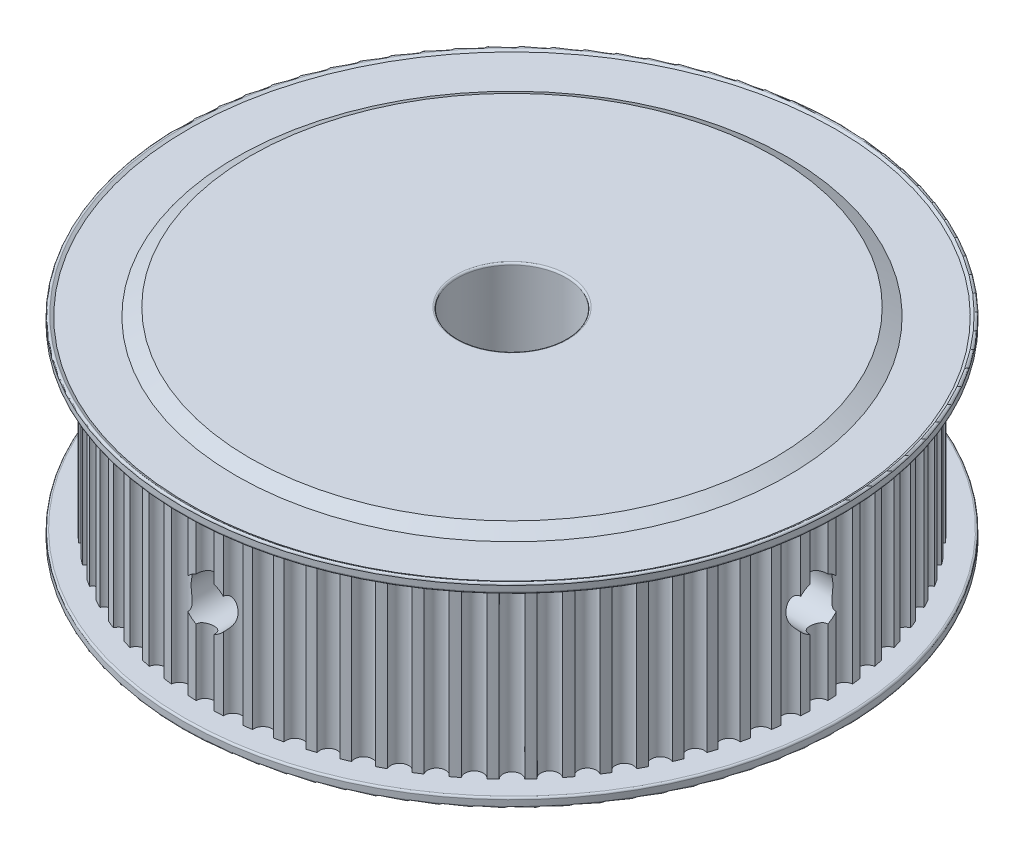
from build123d import *

# Parameters (mm, degrees)
FILLET1_R            = 0.2
BOSS_EXTRUDE1_DEPTH  = 19.5
FILLET1_OF_MIRROR1_R = 0.2
SKETCH4_R            = 2.6
CUT_EXTRUDE1_DEPTH   = 36.5
SKETCH5_R            = 2.6
CUT_EXTRUDE2_DEPTH   = 36.5
SKETCH3_R            = 6
CUT_EXTRUDE3_DEPTH   = 24
FILLET2_R            = 0.2
SCALE2_SCALE         = 0.2


with BuildPart() as part:
    # Sketch1 → Revolve1 (revolve)
    with BuildSketch(Plane.XY):
        Polygon((0, 0), (0, 1.75), (36.5, 1.75), (36.5, 0.55), (35.893782217, 0.9), (30.558845727, 0.9), (29, 0), align=None)
    revolve1 = revolve(axis=Axis((0, 0, 0), (0, 1, 0)))

    # Fillet1
    fillet1_edges = [part.edges().sort_by_distance(p)[0] for p in [
        (-36.5, 0.55, 0),
        (-36.5, 1.75, 0),
    ]]
    fillet(fillet1_edges, radius=FILLET1_R)

    # Sketch2 → Boss-Extrude1 (add)
    with BuildSketch(Plane(origin=(0, 1.75, 0), x_dir=(1, 0, 0), z_dir=(0, 1, 0))):
        with BuildLine():
            ThreePointArc((1.965926579, 33.943116131), (1.48305917, 33.967639534), (0.999891863, 33.985294118))
            ThreePointArc((0.999891863, 33.985294118), (0, 33), (-0.999891863, 33.985294118))
            ThreePointArc((-0.999891863, 33.985294118), (-1.48305917, 33.967639534), (-1.965926579, 33.943116131))
            ThreePointArc((-1.965926579, 33.943116131), (-2.876139511, 32.874425037), (-3.958100524, 33.768823495))
            ThreePointArc((-3.958100524, 33.768823495), (-4.437890535, 33.709125287), (-4.916783132, 33.642610535))
            ThreePointArc((-4.916783132, 33.642610535), (-5.730389863, 32.498655849), (-6.88618565, 33.295351736))
            ThreePointArc((-6.88618565, 33.295351736), (-7.358946874, 33.194064242), (-7.830219997, 33.086064359))
            ThreePointArc((-7.830219997, 33.086064359), (-8.541028488, 31.875552268), (-9.761862745, 32.568482245))
            ThreePointArc((-9.761862745, 32.568482245), (-10.223997183, 32.426376325), (-10.68406416, 32.277713256))
            ThreePointArc((-10.68406416, 32.277713256), (-11.28666473, 31.009856486), (-12.56324617, 31.593746939))
            ThreePointArc((-12.56324617, 31.593746939), (-13.0112367, 31.411904105), (-13.456596143, 31.223709264))
            ThreePointArc((-13.456596143, 31.223709264), (-13.946402637, 29.908156972), (-15.269015706, 30.378564143))
            ThreePointArc((-15.269015706, 30.378564143), (-15.69945285, 30.158368328), (-16.126715305, 29.932073992))
            ThreePointArc((-16.126715305, 29.932073992), (-16.5, 28.578838325), (-17.858578813, 28.93218213))
            ThreePointArc((-17.858578813, 28.93218213), (-18.268186684, 28.675309158), (-18.674100425, 28.412637564))
            ThreePointArc((-18.674100425, 28.412637564), (-18.9280224, 27.032017462), (-20.312227352, 27.265608741))
            ThreePointArc((-20.312227352, 27.265608741), (-20.697888586, 26.97401357), (-21.079364365, 26.676963807))
            ThreePointArc((-21.079364365, 26.676963807), (-21.21199112, 25.279466623), (-22.611287575, 25.391527606))
            ThreePointArc((-22.611287575, 25.391527606), (-22.970067059, 25.067429452), (-23.324201615, 24.738262248))
            ThreePointArc((-23.324201615, 24.738262248), (-23.334523779, 23.334523779), (-24.738262248, 23.324201615))
            ThreePointArc((-24.738262248, 23.324201615), (-25.067429452, 22.970067059), (-25.391527606, 22.611287575))
            ThreePointArc((-25.391527606, 22.611287575), (-25.279466623, 21.21199112), (-26.676963807, 21.079364365))
            ThreePointArc((-26.676963807, 21.079364365), (-26.97401357, 20.697888586), (-27.265608741, 20.312227352))
            ThreePointArc((-27.265608741, 20.312227352), (-27.032017462, 18.9280224), (-28.412637564, 18.674100425))
            ThreePointArc((-28.412637564, 18.674100425), (-28.675309158, 18.268186684), (-28.93218213, 17.858578813))
            ThreePointArc((-28.93218213, 17.858578813), (-28.578838325, 16.5), (-29.932073992, 16.126715305))
            ThreePointArc((-29.932073992, 16.126715305), (-30.158368328, 15.69945285), (-30.378564143, 15.269015706))
            ThreePointArc((-30.378564143, 15.269015706), (-29.908156972, 13.946402637), (-31.223709264, 13.456596143))
            ThreePointArc((-31.223709264, 13.456596143), (-31.411904105, 13.0112367), (-31.593746939, 12.56324617))
            ThreePointArc((-31.593746939, 12.56324617), (-31.009856486, 11.28666473), (-32.277713256, 10.68406416))
            ThreePointArc((-32.277713256, 10.68406416), (-32.426376325, 10.223997183), (-32.568482245, 9.761862745))
            ThreePointArc((-32.568482245, 9.761862745), (-31.875552268, 8.541028488), (-33.086064359, 7.830219997))
            ThreePointArc((-33.086064359, 7.830219997), (-33.194064242, 7.358946874), (-33.295351736, 6.88618565))
            ThreePointArc((-33.295351736, 6.88618565), (-32.498655849, 5.730389863), (-33.642610535, 4.916783132))
            ThreePointArc((-33.642610535, 4.916783132), (-33.709125287, 4.437890535), (-33.768823495, 3.958100524))
            ThreePointArc((-33.768823495, 3.958100524), (-32.874425037, 2.876139511), (-33.943116131, 1.965926579))
            ThreePointArc((-33.943116131, 1.965926579), (-33.967639534, 1.48305917), (-33.985294118, 0.999891863))
            ThreePointArc((-33.985294118, 0.999891863), (-33, 0), (-33.985294118, -0.999891863))
            ThreePointArc((-33.985294118, -0.999891863), (-33.967639534, -1.48305917), (-33.943116131, -1.965926579))
            ThreePointArc((-33.943116131, -1.965926579), (-32.874425037, -2.876139511), (-33.768823495, -3.958100524))
            ThreePointArc((-33.768823495, -3.958100524), (-33.709125287, -4.437890535), (-33.642610535, -4.916783132))
            ThreePointArc((-33.642610535, -4.916783132), (-32.498655849, -5.730389863), (-33.295351736, -6.88618565))
            ThreePointArc((-33.295351736, -6.88618565), (-33.194064242, -7.358946874), (-33.086064359, -7.830219997))
            ThreePointArc((-33.086064359, -7.830219997), (-31.875552268, -8.541028488), (-32.568482245, -9.761862745))
            ThreePointArc((-32.568482245, -9.761862745), (-32.426376325, -10.223997183), (-32.277713256, -10.68406416))
            ThreePointArc((-32.277713256, -10.68406416), (-31.009856486, -11.28666473), (-31.593746939, -12.56324617))
            ThreePointArc((-31.593746939, -12.56324617), (-31.411904105, -13.0112367), (-31.223709264, -13.456596143))
            ThreePointArc((-31.223709264, -13.456596143), (-29.908156972, -13.946402637), (-30.378564143, -15.269015706))
            ThreePointArc((-30.378564143, -15.269015706), (-30.158368328, -15.69945285), (-29.932073992, -16.126715305))
            ThreePointArc((-29.932073992, -16.126715305), (-28.578838325, -16.5), (-28.93218213, -17.858578813))
            ThreePointArc((-28.93218213, -17.858578813), (-28.675309158, -18.268186684), (-28.412637564, -18.674100425))
            ThreePointArc((-28.412637564, -18.674100425), (-27.032017462, -18.9280224), (-27.265608741, -20.312227352))
            ThreePointArc((-27.265608741, -20.312227352), (-26.97401357, -20.697888586), (-26.676963807, -21.079364365))
            ThreePointArc((-26.676963807, -21.079364365), (-25.279466623, -21.21199112), (-25.391527606, -22.611287575))
            ThreePointArc((-25.391527606, -22.611287575), (-25.067429452, -22.970067059), (-24.738262248, -23.324201615))
            ThreePointArc((-24.738262248, -23.324201615), (-23.334523779, -23.334523779), (-23.324201615, -24.738262248))
            ThreePointArc((-23.324201615, -24.738262248), (-22.970067059, -25.067429452), (-22.611287575, -25.391527606))
            ThreePointArc((-22.611287575, -25.391527606), (-21.21199112, -25.279466623), (-21.079364365, -26.676963807))
            ThreePointArc((-21.079364365, -26.676963807), (-20.697888586, -26.97401357), (-20.312227352, -27.265608741))
            ThreePointArc((-20.312227352, -27.265608741), (-18.9280224, -27.032017462), (-18.674100425, -28.412637564))
            ThreePointArc((-18.674100425, -28.412637564), (-18.268186684, -28.675309158), (-17.858578813, -28.93218213))
            ThreePointArc((-17.858578813, -28.93218213), (-16.5, -28.578838325), (-16.126715305, -29.932073992))
            ThreePointArc((-16.126715305, -29.932073992), (-15.69945285, -30.158368328), (-15.269015706, -30.378564143))
            ThreePointArc((-15.269015706, -30.378564143), (-13.946402637, -29.908156972), (-13.456596143, -31.223709264))
            ThreePointArc((-13.456596143, -31.223709264), (-13.0112367, -31.411904105), (-12.56324617, -31.593746939))
            ThreePointArc((-12.56324617, -31.593746939), (-11.28666473, -31.009856486), (-10.68406416, -32.277713256))
            ThreePointArc((-10.68406416, -32.277713256), (-10.223997183, -32.426376325), (-9.761862745, -32.568482245))
            ThreePointArc((-9.761862745, -32.568482245), (-8.541028488, -31.875552268), (-7.830219997, -33.086064359))
            ThreePointArc((-7.830219997, -33.086064359), (-7.358946874, -33.194064242), (-6.88618565, -33.295351736))
            ThreePointArc((-6.88618565, -33.295351736), (-5.730389863, -32.498655849), (-4.916783132, -33.642610535))
            ThreePointArc((-4.916783132, -33.642610535), (-4.437890535, -33.709125287), (-3.958100524, -33.768823495))
            ThreePointArc((-3.958100524, -33.768823495), (-2.876139511, -32.874425037), (-1.965926579, -33.943116131))
            ThreePointArc((-1.965926579, -33.943116131), (-1.48305917, -33.967639534), (-0.999891863, -33.985294118))
            ThreePointArc((-0.999891863, -33.985294118), (0, -33), (0.999891863, -33.985294118))
            ThreePointArc((0.999891863, -33.985294118), (1.48305917, -33.967639534), (1.965926579, -33.943116131))
            ThreePointArc((1.965926579, -33.943116131), (2.876139511, -32.874425037), (3.958100524, -33.768823495))
            ThreePointArc((3.958100524, -33.768823495), (4.437890535, -33.709125287), (4.916783132, -33.642610535))
            ThreePointArc((4.916783132, -33.642610535), (5.730389863, -32.498655849), (6.88618565, -33.295351736))
            ThreePointArc((6.88618565, -33.295351736), (7.358946874, -33.194064242), (7.830219997, -33.086064359))
            ThreePointArc((7.830219997, -33.086064359), (8.541028488, -31.875552268), (9.761862745, -32.568482245))
            ThreePointArc((9.761862745, -32.568482245), (10.223997183, -32.426376325), (10.68406416, -32.277713256))
            ThreePointArc((10.68406416, -32.277713256), (11.28666473, -31.009856486), (12.56324617, -31.593746939))
            ThreePointArc((12.56324617, -31.593746939), (13.0112367, -31.411904105), (13.456596143, -31.223709264))
            ThreePointArc((13.456596143, -31.223709264), (13.946402637, -29.908156972), (15.269015706, -30.378564143))
            ThreePointArc((15.269015706, -30.378564143), (15.69945285, -30.158368328), (16.126715305, -29.932073992))
            ThreePointArc((16.126715305, -29.932073992), (16.5, -28.578838325), (17.858578813, -28.93218213))
            ThreePointArc((17.858578813, -28.93218213), (18.268186684, -28.675309158), (18.674100425, -28.412637564))
            ThreePointArc((18.674100425, -28.412637564), (18.9280224, -27.032017462), (20.312227352, -27.265608741))
            ThreePointArc((20.312227352, -27.265608741), (20.697888586, -26.97401357), (21.079364365, -26.676963807))
            ThreePointArc((21.079364365, -26.676963807), (21.21199112, -25.279466623), (22.611287575, -25.391527606))
            ThreePointArc((22.611287575, -25.391527606), (22.970067059, -25.067429452), (23.324201615, -24.738262248))
            ThreePointArc((23.324201615, -24.738262248), (23.334523779, -23.334523779), (24.738262248, -23.324201615))
            ThreePointArc((24.738262248, -23.324201615), (25.067429452, -22.970067059), (25.391527606, -22.611287575))
            ThreePointArc((25.391527606, -22.611287575), (25.279466623, -21.21199112), (26.676963807, -21.079364365))
            ThreePointArc((26.676963807, -21.079364365), (26.97401357, -20.697888586), (27.265608741, -20.312227352))
            ThreePointArc((27.265608741, -20.312227352), (27.032017462, -18.9280224), (28.412637564, -18.674100425))
            ThreePointArc((28.412637564, -18.674100425), (28.675309158, -18.268186684), (28.93218213, -17.858578813))
            ThreePointArc((28.93218213, -17.858578813), (28.578838325, -16.5), (29.932073992, -16.126715305))
            ThreePointArc((29.932073992, -16.126715305), (30.158368328, -15.69945285), (30.378564143, -15.269015706))
            ThreePointArc((30.378564143, -15.269015706), (29.908156972, -13.946402637), (31.223709264, -13.456596143))
            ThreePointArc((31.223709264, -13.456596143), (31.411904105, -13.0112367), (31.593746939, -12.56324617))
            ThreePointArc((31.593746939, -12.56324617), (31.009856486, -11.28666473), (32.277713256, -10.68406416))
            ThreePointArc((32.277713256, -10.68406416), (32.426376325, -10.223997183), (32.568482245, -9.761862745))
            ThreePointArc((32.568482245, -9.761862745), (31.875552268, -8.541028488), (33.086064359, -7.830219997))
            ThreePointArc((33.086064359, -7.830219997), (33.194064242, -7.358946874), (33.295351736, -6.88618565))
            ThreePointArc((33.295351736, -6.88618565), (32.498655849, -5.730389863), (33.642610535, -4.916783132))
            ThreePointArc((33.642610535, -4.916783132), (33.709125287, -4.437890535), (33.768823495, -3.958100524))
            ThreePointArc((33.768823495, -3.958100524), (32.874425037, -2.876139511), (33.943116131, -1.965926579))
            ThreePointArc((33.943116131, -1.965926579), (33.967639534, -1.48305917), (33.985294118, -0.999891863))
            ThreePointArc((33.985294118, -0.999891863), (33, 0), (33.985294118, 0.999891863))
            ThreePointArc((33.985294118, 0.999891863), (33.967639534, 1.48305917), (33.943116131, 1.965926579))
            ThreePointArc((33.943116131, 1.965926579), (32.874425037, 2.876139511), (33.768823495, 3.958100524))
            ThreePointArc((33.768823495, 3.958100524), (33.709125287, 4.437890535), (33.642610535, 4.916783132))
            ThreePointArc((33.642610535, 4.916783132), (32.498655849, 5.730389863), (33.295351736, 6.88618565))
            ThreePointArc((33.295351736, 6.88618565), (33.194064242, 7.358946874), (33.086064359, 7.830219997))
            ThreePointArc((33.086064359, 7.830219997), (31.875552268, 8.541028488), (32.568482245, 9.761862745))
            ThreePointArc((32.568482245, 9.761862745), (32.426376325, 10.223997183), (32.277713256, 10.68406416))
            ThreePointArc((32.277713256, 10.68406416), (31.009856486, 11.28666473), (31.593746939, 12.56324617))
            ThreePointArc((31.593746939, 12.56324617), (31.411904105, 13.0112367), (31.223709264, 13.456596143))
            ThreePointArc((31.223709264, 13.456596143), (29.908156972, 13.946402637), (30.378564143, 15.269015706))
            ThreePointArc((30.378564143, 15.269015706), (30.158368328, 15.69945285), (29.932073992, 16.126715305))
            ThreePointArc((29.932073992, 16.126715305), (28.578838325, 16.5), (28.93218213, 17.858578813))
            ThreePointArc((28.93218213, 17.858578813), (28.675309158, 18.268186684), (28.412637564, 18.674100425))
            ThreePointArc((28.412637564, 18.674100425), (27.032017462, 18.9280224), (27.265608741, 20.312227352))
            ThreePointArc((27.265608741, 20.312227352), (26.97401357, 20.697888586), (26.676963807, 21.079364365))
            ThreePointArc((26.676963807, 21.079364365), (25.279466623, 21.21199112), (25.391527606, 22.611287575))
            ThreePointArc((25.391527606, 22.611287575), (25.067429452, 22.970067059), (24.738262248, 23.324201615))
            ThreePointArc((24.738262248, 23.324201615), (23.334523779, 23.334523779), (23.324201615, 24.738262248))
            ThreePointArc((23.324201615, 24.738262248), (22.970067059, 25.067429452), (22.611287575, 25.391527606))
            ThreePointArc((22.611287575, 25.391527606), (21.21199112, 25.279466623), (21.079364365, 26.676963807))
            ThreePointArc((21.079364365, 26.676963807), (20.697888586, 26.97401357), (20.312227352, 27.265608741))
            ThreePointArc((20.312227352, 27.265608741), (18.9280224, 27.032017462), (18.674100425, 28.412637564))
            ThreePointArc((18.674100425, 28.412637564), (18.268186684, 28.675309158), (17.858578813, 28.93218213))
            ThreePointArc((17.858578813, 28.93218213), (16.5, 28.578838325), (16.126715305, 29.932073992))
            ThreePointArc((16.126715305, 29.932073992), (15.69945285, 30.158368328), (15.269015706, 30.378564143))
            ThreePointArc((15.269015706, 30.378564143), (13.946402637, 29.908156972), (13.456596143, 31.223709264))
            ThreePointArc((13.456596143, 31.223709264), (13.0112367, 31.411904105), (12.56324617, 31.593746939))
            ThreePointArc((12.56324617, 31.593746939), (11.28666473, 31.009856486), (10.68406416, 32.277713256))
            ThreePointArc((10.68406416, 32.277713256), (10.223997183, 32.426376325), (9.761862745, 32.568482245))
            ThreePointArc((9.761862745, 32.568482245), (8.541028488, 31.875552268), (7.830219997, 33.086064359))
            ThreePointArc((7.830219997, 33.086064359), (7.358946874, 33.194064242), (6.88618565, 33.295351736))
            ThreePointArc((6.88618565, 33.295351736), (5.730389863, 32.498655849), (4.916783132, 33.642610535))
            ThreePointArc((4.916783132, 33.642610535), (4.437890535, 33.709125287), (3.958100524, 33.768823495))
            ThreePointArc((3.958100524, 33.768823495), (2.876139511, 32.874425037), (1.965926579, 33.943116131))
        make_face()
    extrude(amount=BOSS_EXTRUDE1_DEPTH)

    # Mirror1: Revolve1 across plane
    add(revolve1.mirror(Plane.ZX.offset(11.5)))

    # Fillet1 of Mirror1
    fillet1_of_mirror1_edges = [part.edges().sort_by_distance(p)[0] for p in [
        (-36.5, 22.45, 0),
        (-36.5, 21.25, 0),
    ]]
    fillet(fillet1_of_mirror1_edges, radius=FILLET1_OF_MIRROR1_R)

    # Sketch4 → Cut-Extrude1 (cut)
    with BuildSketch(Plane.XY):
        with Locations((0, 11.5)):
            Circle(SKETCH4_R)
    extrude(amount=CUT_EXTRUDE1_DEPTH, mode=Mode.SUBTRACT)

    # Sketch5 → Cut-Extrude2 (cut)
    with BuildSketch(Plane(origin=(0, 0, 0), x_dir=(0, 0, -1), z_dir=(1, 0, 0))):
        with Locations((0, 11.5)):
            Circle(SKETCH5_R)
    extrude(amount=CUT_EXTRUDE2_DEPTH, mode=Mode.SUBTRACT)

    # Sketch3 → Cut-Extrude3 (cut, through all)
    with BuildSketch(Plane(origin=(0, 23, 0), x_dir=(1, 0, 0), z_dir=(0, 1, 0))):
        Circle(SKETCH3_R)
    extrude(amount=-CUT_EXTRUDE3_DEPTH, mode=Mode.SUBTRACT)

    # Fillet2
    fillet2_edges = [part.edges().sort_by_distance(p)[0] for p in [
        (-6, 0, 0),
        (-6, 23, 0),
    ]]
    fillet(fillet2_edges, radius=FILLET2_R)


with BuildPart() as part_1:
    # Scale2: scaled about (-0.150087732, 11.500000022, -0.150087739)
    add(part.part.scale(SCALE2_SCALE).moved(Location((-0.120070186, 9.200000018, -0.120070191))))


solid = part_1.part
